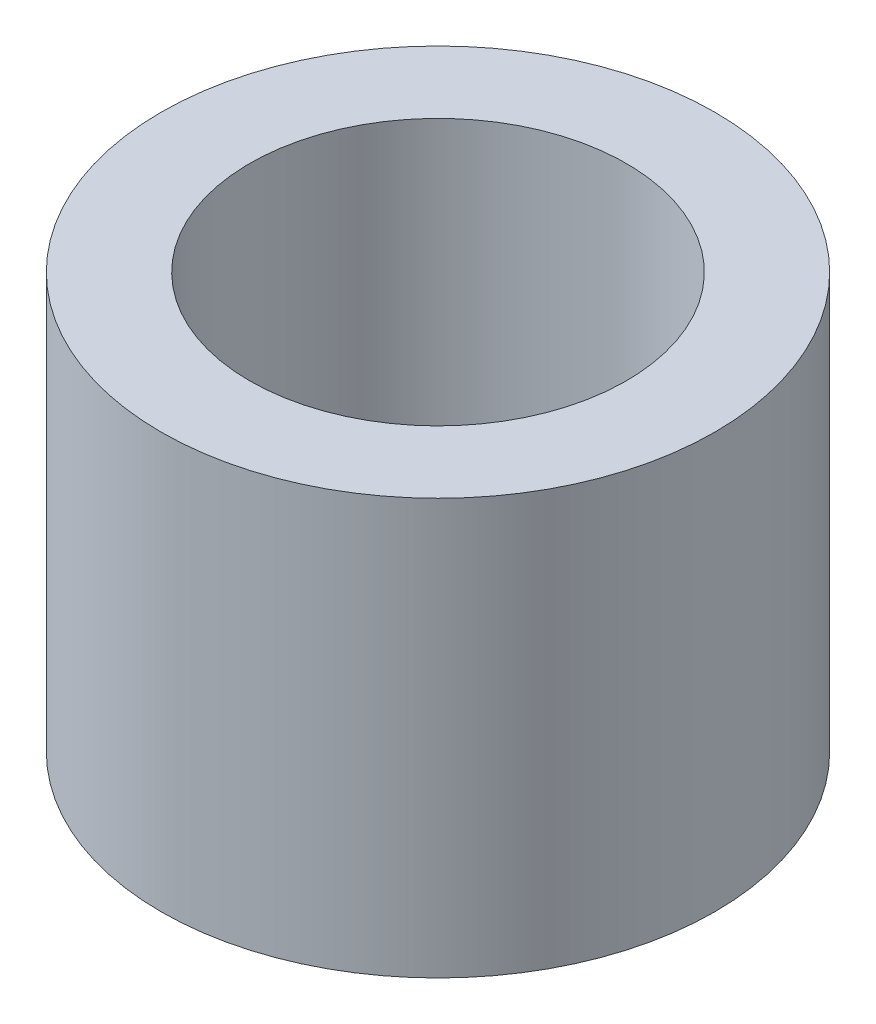
from build123d import *

# Parameters (mm, degrees)
SKETCH1_R           = 3.175
SKETCH1_R_2         = 2.159
BOSS_EXTRUDE1_DEPTH = 4.7625


with BuildPart() as part:
    # Sketch1 → Boss-Extrude1 (new body)
    with BuildSketch(Plane(origin=(0, 0, 0), x_dir=(1, 0, 0), z_dir=(0, 1, 0))):
        Circle(SKETCH1_R)
        Circle(SKETCH1_R_2, mode=Mode.SUBTRACT)
    extrude(amount=BOSS_EXTRUDE1_DEPTH)


solid = part.part
